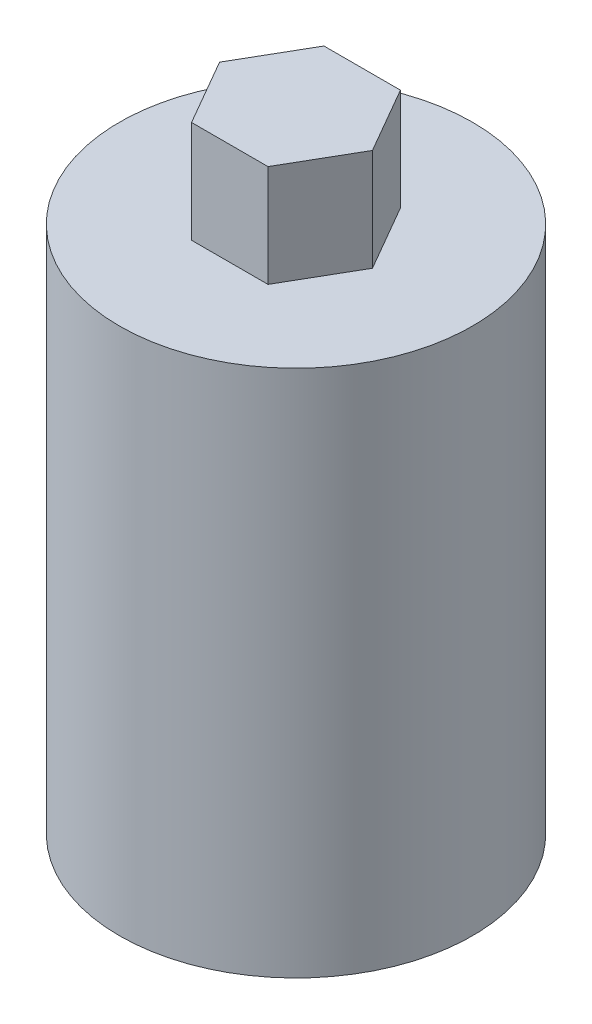
from build123d import *

# Parameters (mm, degrees)
SKETCH1_R           = 6.35
SKETCH1_R_2         = 3
BOSS_EXTRUDE1_DEPTH = 12.5
SKETCH4_R           = 2.413
CUT_EXTRUDE1_DEPTH  = 7.35
SKETCH6_R           = 6.35
BOSS_EXTRUDE4_DEPTH = 6.4925
BOSS_EXTRUDE5_DEPTH = 3.67


with BuildPart() as part:
    # Sketch1 → Boss-Extrude1 (new body)
    with BuildSketch(Plane(origin=(0, 0, 0), x_dir=(1, 0, 0), z_dir=(0, 1, 0))):
        Circle(SKETCH1_R)
        Circle(SKETCH1_R_2, mode=Mode.SUBTRACT)
    extrude(amount=BOSS_EXTRUDE1_DEPTH)

    # Sketch4 → Cut-Extrude1 (cut, through all)
    with BuildSketch(Plane(origin=(0, 0, 0), x_dir=(0, 0, -1), z_dir=(1, 0, 0))):
        with Locations((0, 9.96)):
            Circle(SKETCH4_R)
    extrude(amount=-CUT_EXTRUDE1_DEPTH, mode=Mode.SUBTRACT)

    # Sketch6 → Boss-Extrude4 (add)
    with BuildSketch(Plane(origin=(0, 12.5, 0), x_dir=(1, 0, 0), z_dir=(0, 1, 0))):
        Circle(SKETCH6_R)
    extrude(amount=BOSS_EXTRUDE4_DEPTH)

    # Sketch7 → Boss-Extrude5 (add)
    with BuildSketch(Plane(origin=(0, 18.9925, 0), x_dir=(1, 0, 0), z_dir=(0, 1, 0))):
        Polygon((-1.3748, 2.38122345), (-2.7496, 0), (-1.3748, -2.38122345), (1.3748, -2.38122345), (2.7496, 0), (1.3748, 2.38122345), align=None)
    extrude(amount=BOSS_EXTRUDE5_DEPTH)


solid = part.part
